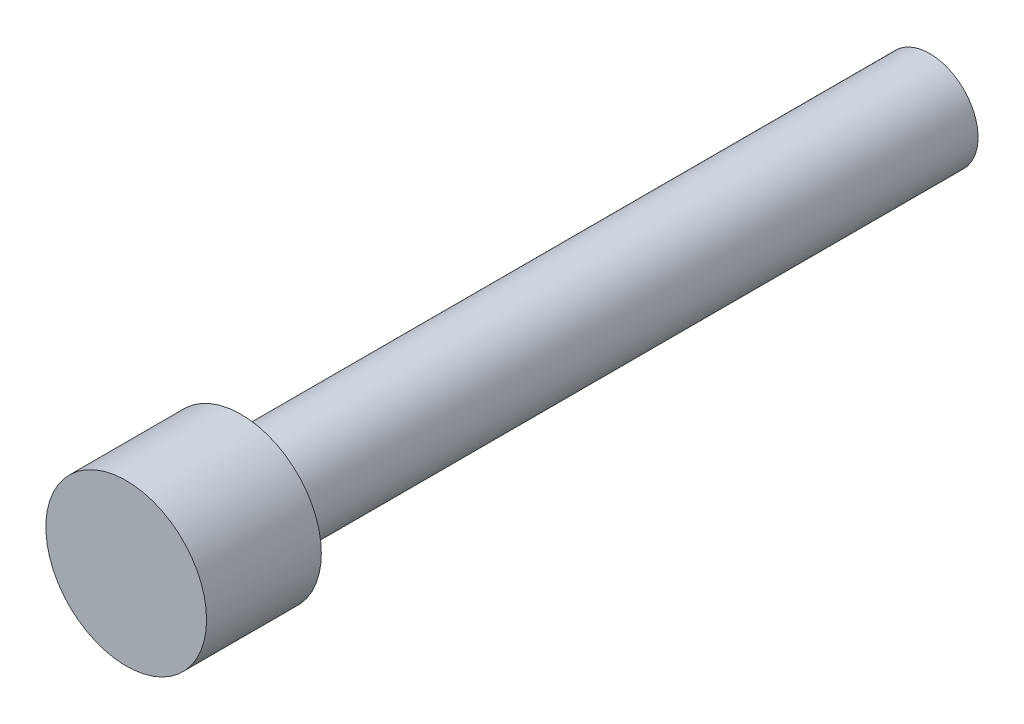
from build123d import *

# Parameters (mm, degrees)
SKETCH1_R           = 1.5875
BOSS_EXTRUDE1_DEPTH = 19.05
SKETCH2_R           = 2.2225
BOSS_EXTRUDE2_DEPTH = 3.175
MOVE_FACE1_BY       = 0.250000008


with BuildPart() as part:
    # Sketch1 → Boss-Extrude1 (new body)
    with BuildSketch(Plane.XY):
        with Locations(Location((0, 0, 0), (0, 0, 180))):
            Circle(SKETCH1_R)
    extrude(amount=BOSS_EXTRUDE1_DEPTH)

    # Sketch2 → Boss-Extrude2 (add)
    with BuildSketch(Plane.XY.offset(19.05)):
        Circle(SKETCH2_R)
    extrude(amount=BOSS_EXTRUDE2_DEPTH)

    # Move Face1: a curved face moved inward by 0.25
    add(Solid.thicken(part.faces().sort_by_distance((1.5875, 0, 9.525))[0], -MOVE_FACE1_BY), mode=Mode.SUBTRACT)


solid = part.part
